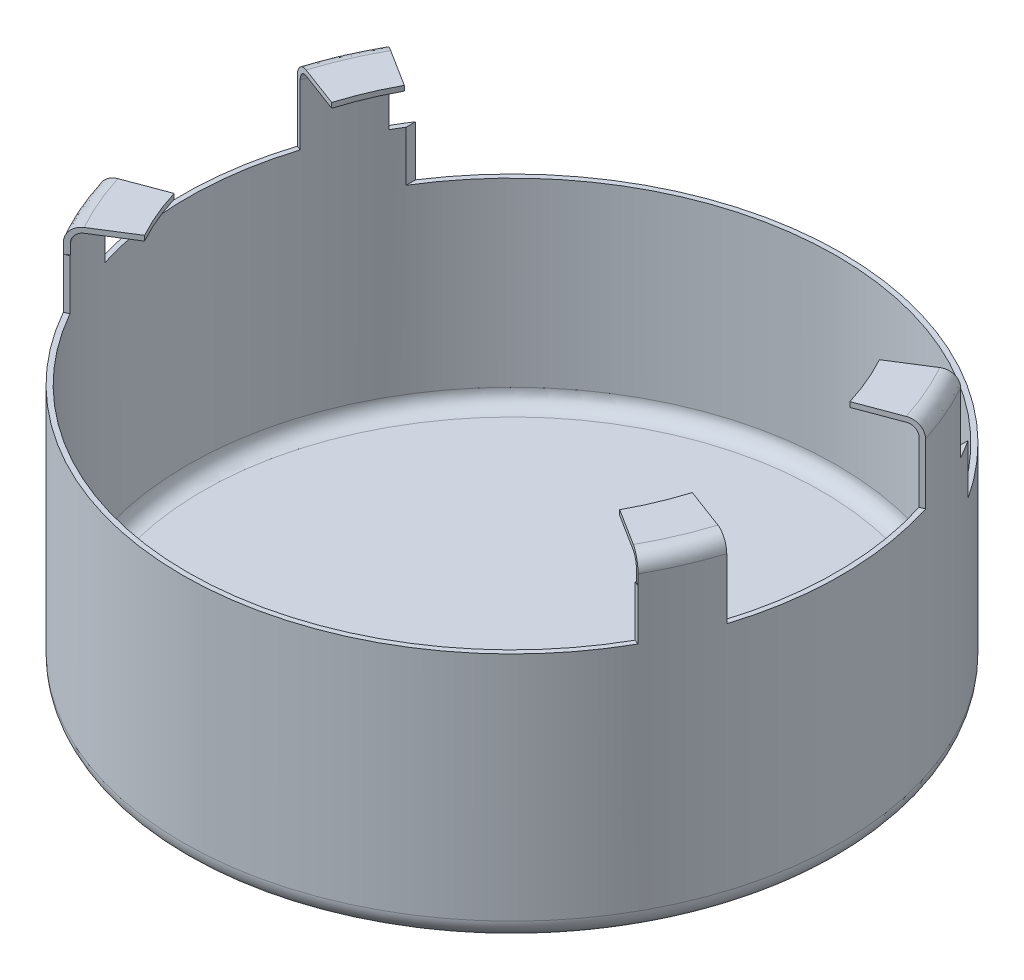
from build123d import *

# Parameters (mm, degrees)
SKETCH1_R           = 8.3185
BOSS_EXTRUDE1_DEPTH = 6.35
FILLET1_R           = 0.508
SHELL1_T            = -0.127
SKETCH11_W          = 13.94567027
SKETCH11_H          = 5.377156333
CUT_EXTRUDE1_DEPTH  = 9.144
BOSS_EXTRUDE2_DEPTH = 1.27
SKETCH14_R          = 2.413
SKETCH14_R_2        = 2.316819153
CUT_EXTRUDE2_DEPTH  = 0.0254


with BuildPart() as part:
    # Sketch1 → Boss-Extrude1 (new body)
    with BuildSketch(Plane(origin=(0, 0, 0), x_dir=(1, 0, 0), z_dir=(0, 1, 0))):
        with Locations(Location((0, 0, 0), (0, 0, 270))):
            Circle(SKETCH1_R)
    extrude(amount=BOSS_EXTRUDE1_DEPTH)

    # Fillet1
    fillet1_edges = [part.edges().sort_by_distance(p)[0] for p in [
        (0, 0, -8.3185),
    ]]
    fillet(fillet1_edges, radius=FILLET1_R)

    # Shell1
    shell1_openings = [part.faces().sort_by_distance(p)[0] for p in [
        (0, 6.35, 0),
    ]]
    offset(amount=SHELL1_T, openings=shell1_openings, kind=Kind.INTERSECTION)

    # Sketch11 → Cut-Extrude1 (cut)
    with BuildSketch(Plane.XY):
        with Locations((0, 7.768578167)):
            Rectangle(SKETCH11_W, SKETCH11_H)
    extrude(amount=-CUT_EXTRUDE1_DEPTH, mode=Mode.SUBTRACT)

    # Sketch12 → Boss-Extrude2 (add)
    with BuildSketch(Plane(origin=(0, 6.35, 0), x_dir=(1, 0, 0), z_dir=(0, 1, 0))):
        with BuildLine():
            Line((-7.133425829, 4.026773918), (-7.253796585, 4.071839554))
            ThreePointArc((-7.253796585, 4.071839554), (-7.632439491, 3.308067361), (-7.930925759, 2.509553516))
            Line((-7.930925759, 2.509553516), (-7.811826035, 2.464963741))
            ThreePointArc((-7.811826035, 2.464963741), (-7.513318247, 3.263544265), (-7.133425829, 4.026773918))
        make_face()
        with BuildLine():
            Line((7.811826035, 2.464963741), (7.930925759, 2.509553516))
            ThreePointArc((7.930925759, 2.509553516), (7.632439491, 3.308067361), (7.253796585, 4.071839554))
            Line((7.253796585, 4.071839554), (7.133425829, 4.026773918))
            ThreePointArc((7.133425829, 4.026773918), (7.513318247, 3.263544265), (7.811826035, 2.464963741))
        make_face()
        with BuildLine():
            Line((7.133425829, -4.026773918), (7.253796585, -4.071839554))
            ThreePointArc((7.253796585, -4.071839554), (7.632439491, -3.308067361), (7.930925759, -2.509553516))
            Line((7.930925759, -2.509553516), (7.811826035, -2.464963741))
            ThreePointArc((7.811826035, -2.464963741), (7.513318247, -3.263544265), (7.133425829, -4.026773918))
        make_face()
        with BuildLine():
            Line((-7.811826035, -2.464963741), (-7.930925759, -2.509553516))
            ThreePointArc((-7.930925759, -2.509553516), (-7.632439491, -3.308067361), (-7.253796585, -4.071839554))
            Line((-7.253796585, -4.071839554), (-7.133425829, -4.026773918))
            ThreePointArc((-7.133425829, -4.026773918), (-7.513318247, -3.263544265), (-7.811826035, -2.464963741))
        make_face()
    extrude(amount=BOSS_EXTRUDE2_DEPTH)

    # Sweep1: sweep along a curve in space
    with BuildLine() as sweep1_path:
        ThreePointArc((-7.253796585, 7.62, -4.071839554), (-7.632439491, 7.62, -3.308067361), (-7.930925759, 7.62, -2.509553516))
    # Sketch13 → Sweep1 (sweep)
    with BuildSketch(Plane(origin=(-0.150951504, 0, 0.403192943), x_dir=(0.9365167851453156, 0, 0.35062274760928275), z_dir=(-0.35062274760928275, 0, 0.9365167851453156))):
        with BuildLine():
            Line((-8.180178564, 7.62), (-8.180178564, 7.880813702))
            ThreePointArc((-8.180178564, 7.880813702), (-8.105783687, 8.060418825), (-7.926178564, 8.134813702))
            Line((-7.926178564, 8.134813702), (-6.82245156, 8.134813702))
            Line((-6.82245156, 8.134813702), (-6.82245156, 8.261813702))
            Line((-6.82245156, 8.261813702), (-7.926351644, 8.261813702))
            ThreePointArc((-7.926351644, 8.261813702), (-8.195759328, 8.150221386), (-8.307351644, 7.880813702))
            Line((-8.307351644, 7.880813702), (-8.307351644, 7.62))
            Line((-8.307351644, 7.62), (-8.180178564, 7.62))
        make_face()
    sweep1 = sweep(path=sweep1_path.line)

    # Mirror1: Sweep1 across plane
    add(sweep1.mirror(Plane(origin=(0, 0, 0), x_dir=(0, 0, 1), z_dir=(1, 0, 0))))

    # Mirror2: Sweep1 across plane
    add(sweep1.mirror(Plane.XY))

    # Mirror2 copy 1: sweep along a curve in space
    with BuildLine() as mirror2_copy_1_path:
        ThreePointArc((7.253796585, 7.62, 4.071839554), (7.632439491, 7.62, 3.308067361), (7.930925759, 7.62, 2.509553516))
    # Mirror2 copy 1 sketch → Mirror2 copy 1 (sweep)
    with BuildSketch(Plane(origin=(0.150951504, 0, -0.403192943), x_dir=(-0.9365167851453156, 0, -0.35062274760928275), z_dir=(0.35062274760928275, 0, -0.9365167851453156))):
        with BuildLine():
            Line((-8.180178564, 7.62), (-8.180178564, 7.880813702))
            ThreePointArc((-8.180178564, 7.880813702), (-8.105783687, 8.060418825), (-7.926178564, 8.134813702))
            Line((-7.926178564, 8.134813702), (-6.82245156, 8.134813702))
            Line((-6.82245156, 8.134813702), (-6.82245156, 8.261813702))
            Line((-6.82245156, 8.261813702), (-7.926351644, 8.261813702))
            ThreePointArc((-7.926351644, 8.261813702), (-8.195759328, 8.150221386), (-8.307351644, 7.880813702))
            Line((-8.307351644, 7.880813702), (-8.307351644, 7.62))
            Line((-8.307351644, 7.62), (-8.180178564, 7.62))
        make_face()
    sweep(path=mirror2_copy_1_path.line)

    # Sketch14 → Cut-Extrude2 (cut)
    with BuildSketch(Plane.XZ):
        with Locations(Location((0, 0, 0), (0, 0, 270))):
            Circle(SKETCH14_R)
        with Locations(Location((0, 0, 0), (0, 0, 270))):
            Circle(SKETCH14_R_2, mode=Mode.SUBTRACT)
    extrude(amount=-CUT_EXTRUDE2_DEPTH, mode=Mode.SUBTRACT)


solid = part.part
